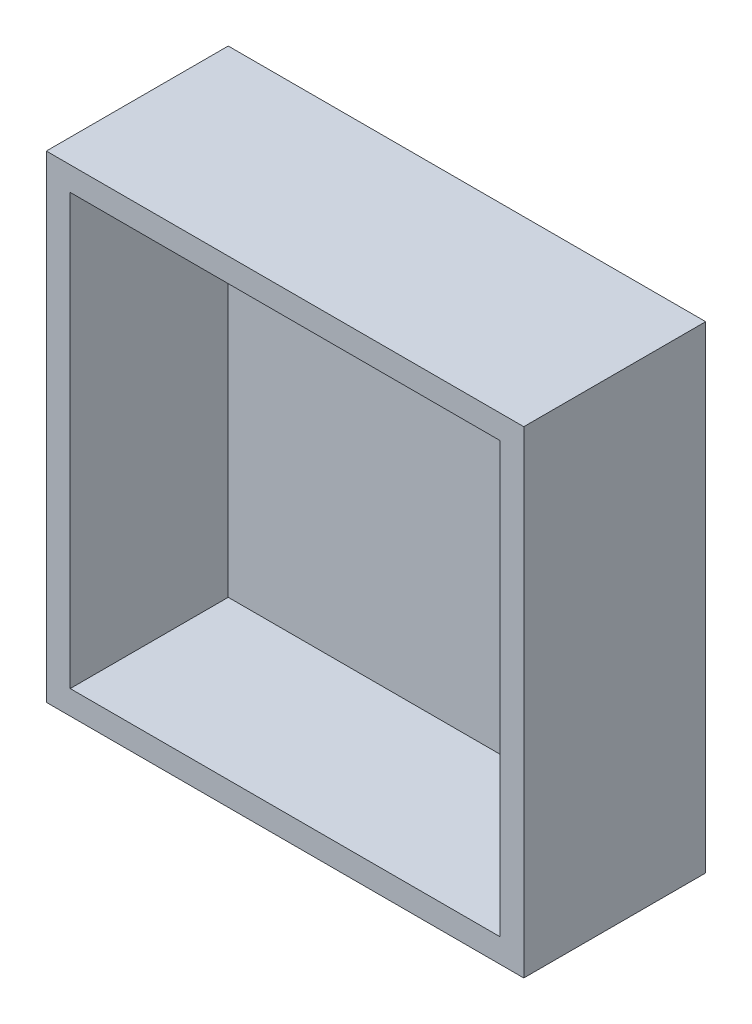
from build123d import *

# Parameters (mm, degrees)
SKETCH1_W           = 200
SKETCH1_H           = 200
BOSS_EXTRUDE1_DEPTH = 76.2
SKETCH2_W           = 180
SKETCH2_H           = 180
CUT_EXTRUDE2_DEPTH  = 80
SKETCH3_W           = 180
SKETCH3_H           = 180
BOSS_EXTRUDE2_DEPTH = 10


with BuildPart() as part:
    # Sketch1 → Boss-Extrude1 (new body)
    with BuildSketch(Plane.XY):
        with Locations((-100, 100)):
            Rectangle(SKETCH1_W, SKETCH1_H)
    extrude(amount=BOSS_EXTRUDE1_DEPTH)

    # Sketch2 → Cut-Extrude2 (cut)
    with BuildSketch(Plane.XY.offset(76.2)):
        with Locations((-100, 100)):
            Rectangle(SKETCH2_W, SKETCH2_H)
    extrude(amount=-CUT_EXTRUDE2_DEPTH, mode=Mode.SUBTRACT)

    # Sketch3 → Boss-Extrude2 (add)
    with BuildSketch(Plane.XY):
        with Locations((-100, 100)):
            Rectangle(SKETCH3_W, SKETCH3_H)
    extrude(amount=BOSS_EXTRUDE2_DEPTH)


solid = part.part
